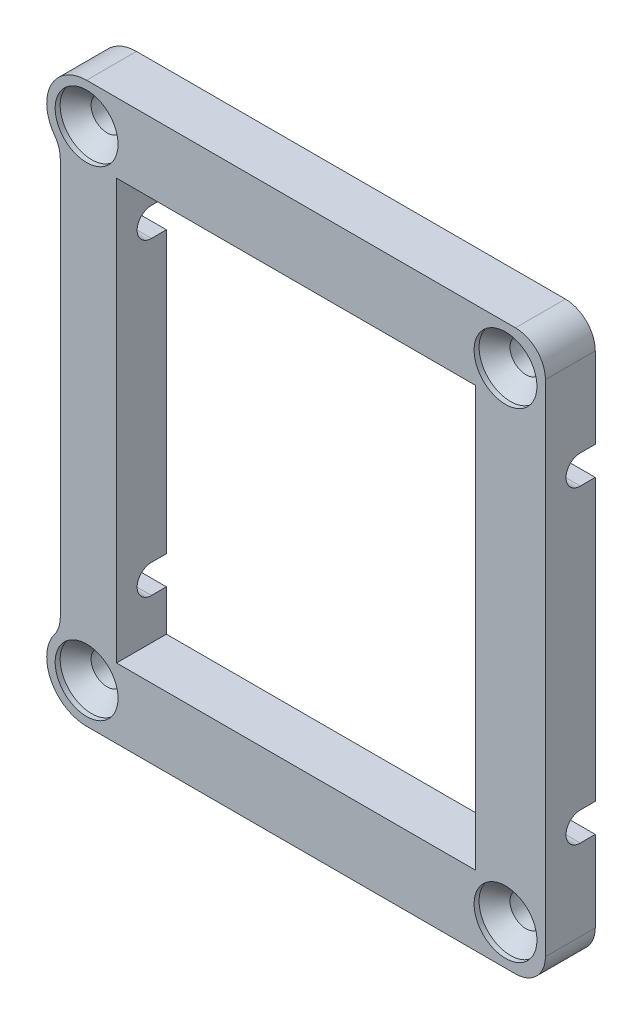
from build123d import *

# Parameters (mm, degrees)
SKETCH1_R                                    = 1.25
SKETCH1_W                                    = 36
SKETCH1_H                                    = 42.1
BOSS_EXTRUDE1_DEPTH                          = 5
CSK_FOR_M3_COUNTERSUNK_FLAT_HEAD_SCR_2_COUNT = 2
CSK_FOR_M3_COUNTERSUNK_FLAT_HEAD_SCR_2_PITCH = 48.1
CSK_FOR_M3_COUNTERSUNK_FLAT_HEAD_SCR_3_COUNT = 2
CSK_FOR_M3_COUNTERSUNK_FLAT_HEAD_SCR_3_PITCH = 63.856166499
CSK_FOR_M3_COUNTERSUNK_FLAT_HEAD_SCR_4_COUNT = 2
CSK_FOR_M3_COUNTERSUNK_FLAT_HEAD_SCR_4_PITCH = 42
FURO_COM_FOLGA_DE_M34_D                      = 2.87
FILETE1_R                                    = 3
ESBO_O3_W                                    = 1.5
ESBO_O3_H                                    = 2.87
CORTE_EXTRUS_O1_DEPTH                        = 63
CORTE_EXTRUS_O1_DEPTH_BACK                   = 10


with BuildPart() as part:
    # Sketch1 → Boss-Extrude1 (new body)
    with BuildSketch(Plane.XY):
        with BuildLine():
            Line((20.053938932, -66.638943184), (63.053938932, -66.638943184))
            ThreePointArc((63.053938932, -66.638943184), (65.175259276, -67.517622841), (66.053938932, -69.638943184))
            Line((66.053938932, -69.638943184), (66.053938932, -119.738943184))
            ThreePointArc((66.053938932, -119.738943184), (65.175259276, -121.860263528), (63.053938932, -122.738943184))
            Line((63.053938932, -122.738943184), (20.053938932, -122.738943184))
            ThreePointArc((20.053938932, -122.738943184), (16.310928808, -120.149572552), (17.413938931, -115.73388079))
            Line((17.413938931, -115.73388079), (17.413938931, -73.644005579))
            ThreePointArc((17.413938931, -73.644005579), (16.310928808, -69.228313817), (20.053938932, -66.638943184))
        make_face()
        with Locations((20.053938932, -70.638943184)):
            Circle(SKETCH1_R, mode=Mode.SUBTRACT)
        with Locations((20.053938932, -118.738943184)):
            Circle(SKETCH1_R, mode=Mode.SUBTRACT)
        with Locations((62.053938932, -70.638943184)):
            Circle(SKETCH1_R, mode=Mode.SUBTRACT)
        with Locations((62.053938932, -118.738943184)):
            Circle(SKETCH1_R, mode=Mode.SUBTRACT)
        with Locations((41.053938932, -94.688943184)):
            Rectangle(SKETCH1_W, SKETCH1_H, mode=Mode.SUBTRACT)
    extrude(amount=BOSS_EXTRUDE1_DEPTH)

    # Sketch2 → CSK for M3 Countersunk Flat Head Screw1 (revolve, cut)
    with BuildSketch(Plane(origin=(20.053938932, -118.738943184, 5), x_dir=(0, -1, 0), z_dir=(1, 0, 0))):
        Polygon((0, 0), (0, 5), (1.6, 5), (1.6, 2.05), (3.15, 0.5), (3.15, 0), align=None)
    csk_for_m3_countersunk_flat_head_screw1 = revolve(axis=Axis((20.053938932, -118.738943184, 11.35), (0, 0, -1)), mode=Mode.SUBTRACT)

    # CSK for M3 Countersunk Flat Head Scr 2: CSK for M3 Countersunk Flat Head Screw1 ×2
    with Locations(*[(0, i * CSK_FOR_M3_COUNTERSUNK_FLAT_HEAD_SCR_2_PITCH, 0) for i in range(1, CSK_FOR_M3_COUNTERSUNK_FLAT_HEAD_SCR_2_COUNT)]):
        add(csk_for_m3_countersunk_flat_head_screw1, mode=Mode.SUBTRACT)

    # CSK for M3 Countersunk Flat Head Scr 3: CSK for M3 Countersunk Flat Head Screw1 ×2
    with Locations(*[Vector(0.657728177, 0.753255365, 0) * (i * CSK_FOR_M3_COUNTERSUNK_FLAT_HEAD_SCR_3_PITCH) for i in range(1, CSK_FOR_M3_COUNTERSUNK_FLAT_HEAD_SCR_3_COUNT)]):
        add(csk_for_m3_countersunk_flat_head_screw1, mode=Mode.SUBTRACT)

    # CSK for M3 Countersunk Flat Head Scr 4: CSK for M3 Countersunk Flat Head Screw1 ×2
    with Locations(*[(i * CSK_FOR_M3_COUNTERSUNK_FLAT_HEAD_SCR_4_PITCH, 0, 0) for i in range(1, CSK_FOR_M3_COUNTERSUNK_FLAT_HEAD_SCR_4_COUNT)]):
        add(csk_for_m3_countersunk_flat_head_screw1, mode=Mode.SUBTRACT)

    # Furo com folga de M34 (through all)
    with Locations(Plane(origin=(66.053938932, 0, 0), x_dir=(0, 0, -1), z_dir=(1, 0, 0))):
        with Locations((-1.5, -79.188943184), (-1.5, -110.188943184)):
            Hole(FURO_COM_FOLGA_DE_M34_D / 2)

    # Filete1
    filete1_edges = [part.edges().sort_by_distance(p)[0] for p in [
        (17.413938931, -115.73388079, 2.5),
        (17.413938931, -73.644005579, 2.5),
    ]]
    fillet(filete1_edges, radius=FILETE1_R)

    # Esboço3 → Corte-extrusão1 (cut, two sides)
    with BuildSketch(Plane.ZY.offset(-59.053938932)) as corte_extrus_o1_sk:
        with Locations((0.75, -79.188943184)):
            Rectangle(ESBO_O3_W, ESBO_O3_H)
        with Locations((0.75, -110.188943184)):
            Rectangle(ESBO_O3_W, ESBO_O3_H)
    extrude(amount=CORTE_EXTRUS_O1_DEPTH, mode=Mode.SUBTRACT)
    extrude(corte_extrus_o1_sk.sketch, amount=-CORTE_EXTRUS_O1_DEPTH_BACK, mode=Mode.SUBTRACT)


solid = part.part
